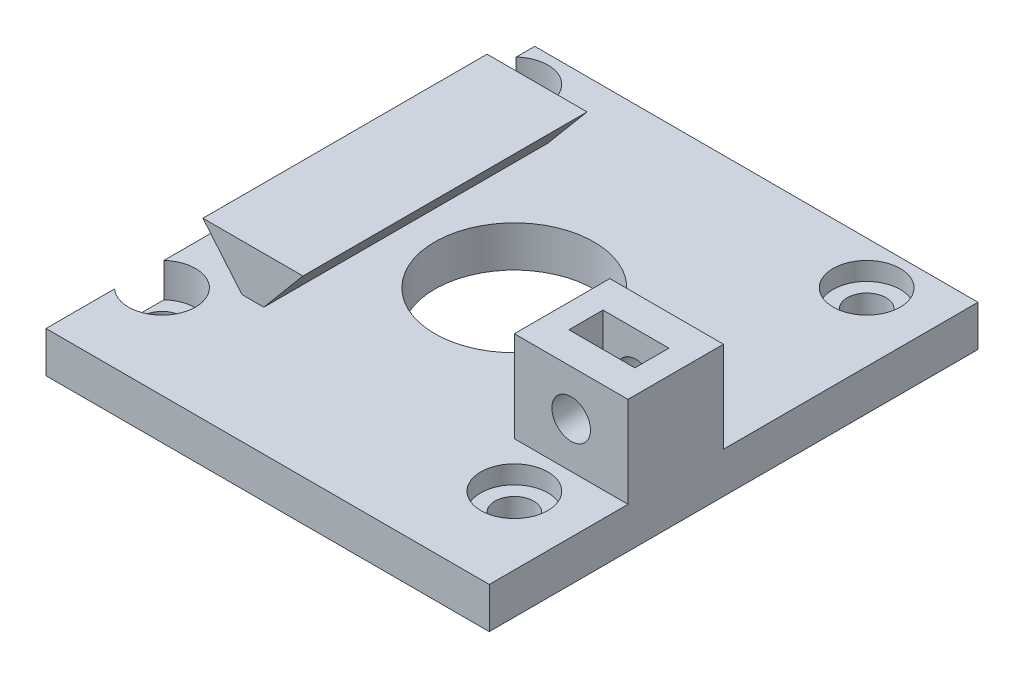
from build123d import *

# Parameters (mm, degrees)
CROQUIS1_W                   = 39
CROQUIS1_H                   = 43
CROQUIS1_R                   = 7
CROQUIS1_R_2                 = 1.7
SALIENTE_EXTRUIR1_DEPTH      = 3.6
CROQUIS2_R                   = 2.95
CORTAR_EXTRUIR1_DEPTH        = 1.6
CROQUIS3_W                   = 10
CROQUIS3_H                   = 8.4
SALIENTE_EXTRUIR2_DEPTH      = 8
CROQUIS4_R                   = 1.7
CORTAR_EXTRUIR2_DEPTH        = 11
CORTAR_EXTRUIR3_DEPTH        = 1.5
CORTAR_EXTRUIR3_DEPTH_BACK   = 1.5
SALIENTE_EXTRUIR3_DEPTH      = 12.5
SALIENTE_EXTRUIR3_DEPTH_BACK = 12.5
CORTAR_EXTRUIR4_DEPTH        = 3


with BuildPart() as part:
    # Croquis1 → Saliente-Extruir1 (new body)
    with BuildSketch(Plane(origin=(0, 0, 0), x_dir=(1, 0, 0), z_dir=(0, 1, 0))):
        with Locations((2, -2.205128205)):
            Rectangle(CROQUIS1_W, CROQUIS1_H)
        Circle(CROQUIS1_R, mode=Mode.SUBTRACT)
        with Locations((-15.5, 15.5)):
            Circle(CROQUIS1_R_2, mode=Mode.SUBTRACT)
        with Locations((15.5, 15.5)):
            Circle(CROQUIS1_R_2, mode=Mode.SUBTRACT)
        with Locations((-15.5, -15.5)):
            Circle(CROQUIS1_R_2, mode=Mode.SUBTRACT)
        with Locations((15.5, -15.5)):
            Circle(CROQUIS1_R_2, mode=Mode.SUBTRACT)
    extrude(amount=SALIENTE_EXTRUIR1_DEPTH)

    # Croquis2 → Cortar-Extruir1 (cut)
    with BuildSketch(Plane(origin=(0, 3.6, 0), x_dir=(1, 0, 0), z_dir=(0, 1, 0))):
        with Locations((-15.5, 15.5)):
            Circle(CROQUIS2_R)
        with Locations((15.5, 15.5)):
            Circle(CROQUIS2_R)
        with Locations((-15.5, -15.5)):
            Circle(CROQUIS2_R)
        with Locations((15.5, -15.5)):
            Circle(CROQUIS2_R)
    extrude(amount=-CORTAR_EXTRUIR1_DEPTH, mode=Mode.SUBTRACT)

    # Croquis3 → Saliente-Extruir2 (add)
    with BuildSketch(Plane(origin=(0, 3.6, 0), x_dir=(1, 0, 0), z_dir=(0, 1, 0))):
        with Locations((16.5, -7.3)):
            Rectangle(CROQUIS3_W, CROQUIS3_H)
    extrude(amount=SALIENTE_EXTRUIR2_DEPTH)

    # Croquis4 → Cortar-Extruir2 (cut)
    with BuildSketch(Plane.XY.offset(11.5)):
        with Locations((16.5, 7.6)):
            Circle(CROQUIS4_R)
    extrude(amount=-CORTAR_EXTRUIR2_DEPTH, mode=Mode.SUBTRACT)

    # Croquis5 → Cortar-Extruir3 (cut, two sides)
    with BuildSketch(Plane.XY.offset(7.3)) as cortar_extruir3_sk:
        Polygon((13.598814897, 9.275), (13.598814897, 15.925), (19.401185103, 15.925), (19.401185103, 9.275), (19.401185103, 5.925), (16.5, 4.25), (13.598814897, 5.925), align=None)
    extrude(amount=CORTAR_EXTRUIR3_DEPTH, mode=Mode.SUBTRACT)
    extrude(cortar_extruir3_sk.sketch, amount=-CORTAR_EXTRUIR3_DEPTH_BACK, mode=Mode.SUBTRACT)

    # Croquis6 → Saliente-Extruir3 (add, two sides)
    with BuildSketch(Plane.XY) as saliente_extruir3_sk:
        Polygon((-10.5, 2.456284193), (-14.9, 7.7), (-6.1, 7.7), align=None)
    extrude(amount=SALIENTE_EXTRUIR3_DEPTH)
    extrude(saliente_extruir3_sk.sketch, amount=-SALIENTE_EXTRUIR3_DEPTH_BACK)

    # Croquis7 → Cortar-Extruir4 (cut)
    with BuildSketch(Plane(origin=(0, 3.6, 0), x_dir=(1, 0, 0), z_dir=(0, 1, 0))):
        with BuildLine():
            Line((-17.5, -13.331475156), (-17.5, -17.668524844))
            ThreePointArc((-17.5, -17.668524844), (-12.55, -15.5), (-17.5, -13.331475156))
        make_face()
        with BuildLine():
            Line((-17.5, 17.668524844), (-17.5, 13.331475156))
            ThreePointArc((-17.5, 13.331475156), (-12.55, 15.5), (-17.5, 17.668524844))
        make_face()
    extrude(amount=-CORTAR_EXTRUIR4_DEPTH, mode=Mode.SUBTRACT)


solid = part.part
